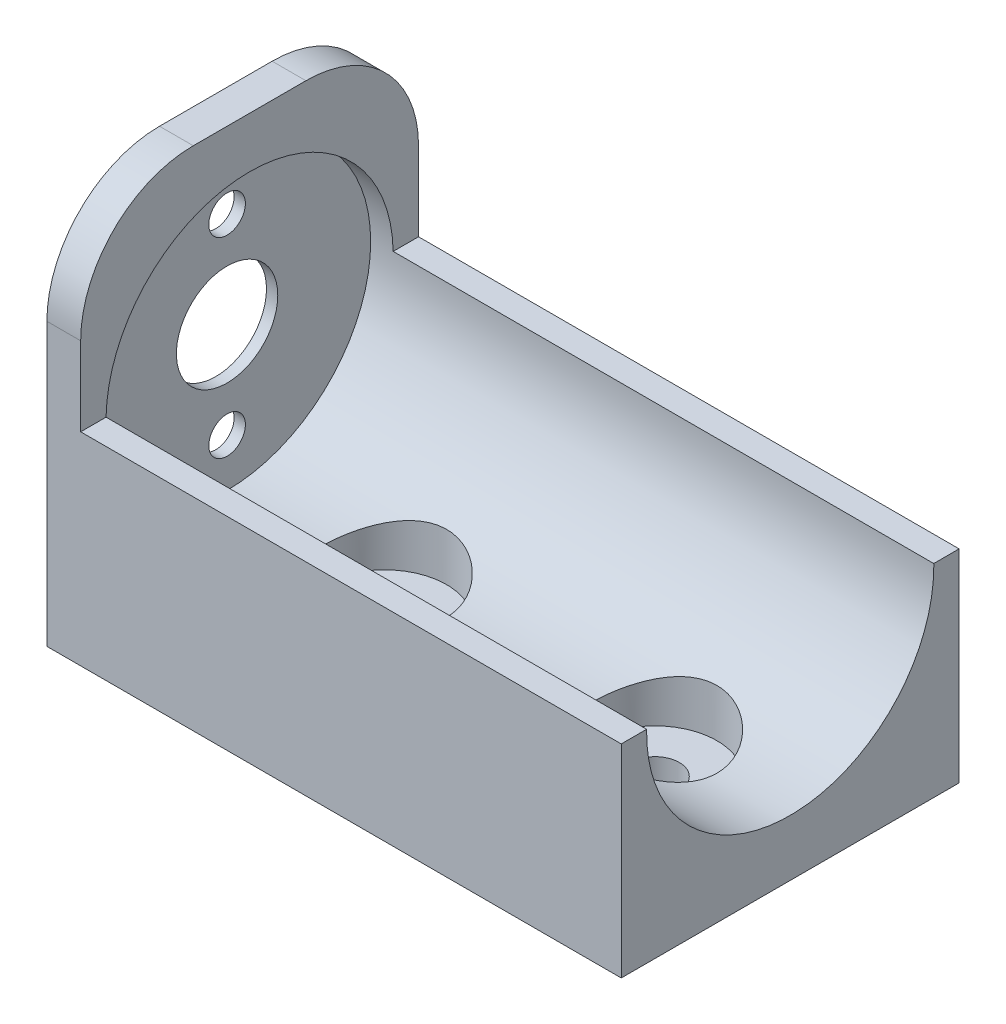
from build123d import *
from build123d.topology import SkipClean

# Parameters (mm, degrees)
SUPPORT_W                                       = 3
SUPPORT_H                                       = 30
BOSS_SUPPORT_AVANT_DEPTH                        = 35
SKETCH2_5_W                                     = 48
SKETCH2_5_H                                     = 30
BOSS_SUUPORT_ARRIERE_DEPTH                      = 18
CUT_SUPPORT_MOTEUR_DEPTH                        = 62.269894728
CUT_SUPPORT_MOTEUR_DEPTH_BACK                   = 2
TROUS_MOTEUR_R                                  = 12.75
CUT_TROUS_MOTEUR_REACH                          = 63.27
SKETCH3_4_R                                     = 1.625
SKETCH3_4_R_2                                   = 4.5
FILLET1_R                                       = 10
CBORE_FOR_6_PAN_HEAD_MACHINE_SCREW3_D           = 4.3053
CBORE_FOR_6_PAN_HEAD_MACHINE_SCREW3_CBORE_D     = 11.000000098
CBORE_FOR_6_PAN_HEAD_MACHINE_SCREW3_CBORE_DEPTH = 3.000000096


with BuildPart() as part:
    # Support → Boss-Support avant (new body)
    with BuildSketch(Plane(origin=(0, 0, 0), x_dir=(1, 0, 0), z_dir=(0, 1, 0))):
        with Locations((1.5, 0)):
            Rectangle(SUPPORT_W, SUPPORT_H)
    extrude(amount=BOSS_SUPPORT_AVANT_DEPTH)

    # Sketch2_5 → Boss-Suuport arriere (add)
    with BuildSketch(Plane(origin=(0, 0, 0), x_dir=(1, 0, 0), z_dir=(0, 1, 0))):
        with Locations((27, 0)):
            Rectangle(SKETCH2_5_W, SKETCH2_5_H)
    extrude(amount=BOSS_SUUPORT_ARRIERE_DEPTH)

    # Trous moteur → Cut-Support moteur (cut, two sides: drawn at the far end of the back side and taken through both)
    with BuildSketch(Plane(origin=(3, 0, 0), x_dir=(0, 0, -1), z_dir=(1, 0, 0)).offset(-CUT_SUPPORT_MOTEUR_DEPTH_BACK)):
        with Locations((0, 17.75)):
            Circle(TROUS_MOTEUR_R)
        with BuildLine():
            ThreePointArc((-4.493050189, 18), (0, 22.25), (4.493050189, 18))
            Line((4.493050189, 18), (-4.493050189, 18))
        make_face(mode=Mode.SUBTRACT)
    extrude(amount=CUT_SUPPORT_MOTEUR_DEPTH + CUT_SUPPORT_MOTEUR_DEPTH_BACK, mode=Mode.SUBTRACT)

    # Sketch3_4 → Cut-Trous moteur (cut, up to next)
    with BuildSketch(Plane(origin=(3, 0, 0), x_dir=(0, 0, -1), z_dir=(1, 0, 0)), mode=Mode.PRIVATE) as cut_trous_moteur_sk1:
        with Locations((0, 26.25)):
            Circle(SKETCH3_4_R)
    cut_trous_moteur_tool1 = extrude(cut_trous_moteur_sk1.sketch, amount=-CUT_TROUS_MOTEUR_REACH, mode=Mode.PRIVATE) & part.part
    # Sketch3_4 → Cut-Trous moteur (cut, up to next)
    with BuildSketch(Plane(origin=(3, 0, 0), x_dir=(0, 0, -1), z_dir=(1, 0, 0)), mode=Mode.PRIVATE) as cut_trous_moteur_sk2:
        with Locations((0, 17.75)):
            Circle(SKETCH3_4_R_2)
    cut_trous_moteur_tool2 = extrude(cut_trous_moteur_sk2.sketch, amount=-CUT_TROUS_MOTEUR_REACH, mode=Mode.PRIVATE) & part.part
    # Sketch3_4 → Cut-Trous moteur (cut, up to next)
    with BuildSketch(Plane(origin=(3, 0, 0), x_dir=(0, 0, -1), z_dir=(1, 0, 0)), mode=Mode.PRIVATE) as cut_trous_moteur_sk3:
        with Locations((0, 9.25)):
            Circle(SKETCH3_4_R)
    cut_trous_moteur_tool3 = extrude(cut_trous_moteur_sk3.sketch, amount=-CUT_TROUS_MOTEUR_REACH, mode=Mode.PRIVATE) & part.part
    add(cut_trous_moteur_tool1.solids().sort_by_distance((3, 26.25, 0))[0], mode=Mode.SUBTRACT)
    add(cut_trous_moteur_tool2.solids().sort_by_distance((3, 17.75, 0))[0], mode=Mode.SUBTRACT)
    add(cut_trous_moteur_tool3.solids().sort_by_distance((3, 9.25, 0))[0], mode=Mode.SUBTRACT)

    # Fillet1
    fillet1_edges = [part.edges().sort_by_distance(p)[0] for p in [
        (1.5, 35, -15),
        (1.5, 35, 15),
    ]]
    fillet(fillet1_edges, radius=FILLET1_R)

    # CBORE for _6 Pan Head Machine Screw3 (through all)
    with Locations(Plane(origin=(39, 5, 0), x_dir=(0, 0, 1), z_dir=(0, 1, 0))):
        with Locations((0, 0), (0, -24)):
            CounterBoreHole(CBORE_FOR_6_PAN_HEAD_MACHINE_SCREW3_D / 2, CBORE_FOR_6_PAN_HEAD_MACHINE_SCREW3_CBORE_D / 2, CBORE_FOR_6_PAN_HEAD_MACHINE_SCREW3_CBORE_DEPTH)


solid = part.part
